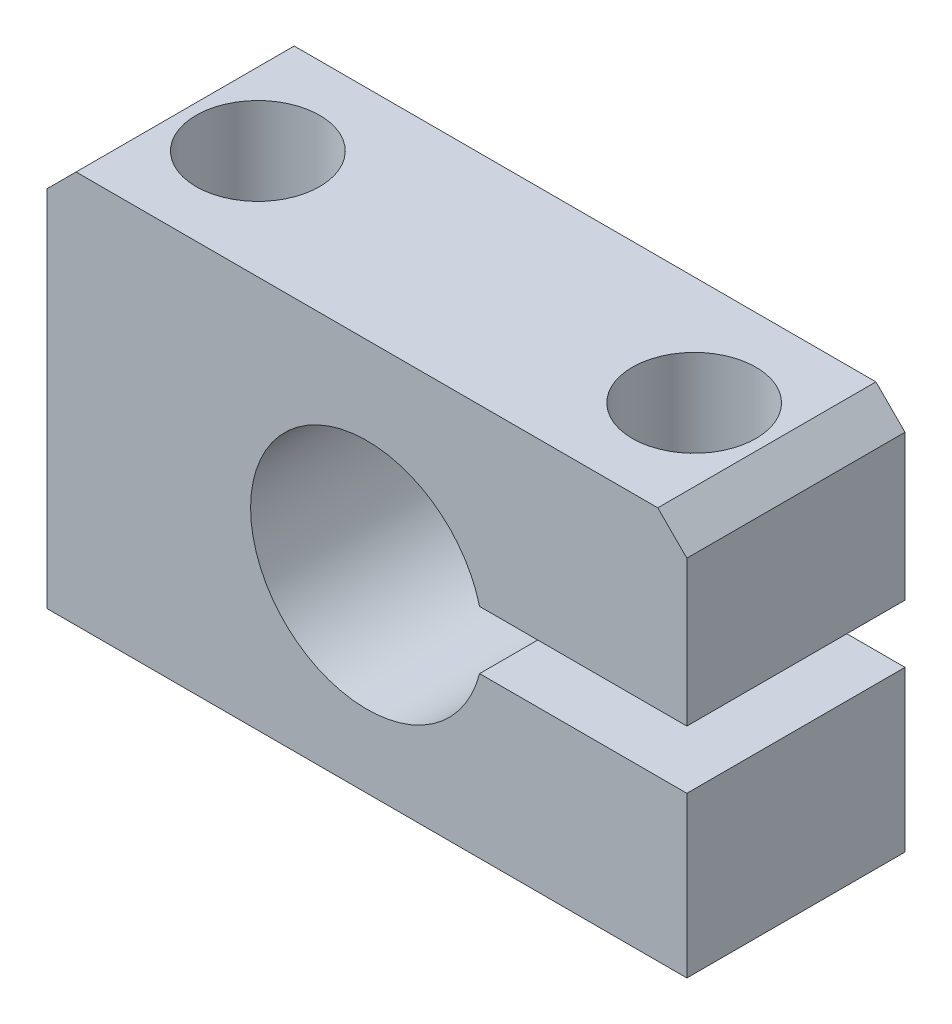
from build123d import *

# Parameters (mm, degrees)
SKETCH1_W                                           = 44
SKETCH1_H                                           = 27
SKETCH1_R                                           = 8
BOSS_EXTRUDE1_DEPTH                                 = 15
CBORE_FOR_M5_HEX_SOCKET_HEAD_CAP_SCREW1_D           = 5.5
CBORE_FOR_M5_HEX_SOCKET_HEAD_CAP_SCREW1_DEPTH       = 27
CBORE_FOR_M5_HEX_SOCKET_HEAD_CAP_SCREW1_CBORE_D     = 8.5
CBORE_FOR_M5_HEX_SOCKET_HEAD_CAP_SCREW1_CBORE_DEPTH = 6
CHAMFER1_SIZE                                       = 2
CUT_EXTRUDE1_REACH                                  = 17


with BuildPart() as part:
    # Sketch1 → Boss-Extrude1 (new body)
    with BuildSketch(Plane.XY):
        with Locations((0, 13.5)):
            Rectangle(SKETCH1_W, SKETCH1_H)
        with Locations((0, 13)):
            Circle(SKETCH1_R, mode=Mode.SUBTRACT)
    extrude(amount=BOSS_EXTRUDE1_DEPTH)

    # CBORE for M5 Hex Socket Head Cap Screw1
    with Locations(Plane(origin=(-15, 27, 7.5), x_dir=(1, 0, 0), z_dir=(0, 1, 0))):
        with Locations((0, 0), (30, 0)):
            CounterBoreHole(CBORE_FOR_M5_HEX_SOCKET_HEAD_CAP_SCREW1_D / 2, CBORE_FOR_M5_HEX_SOCKET_HEAD_CAP_SCREW1_CBORE_D / 2, CBORE_FOR_M5_HEX_SOCKET_HEAD_CAP_SCREW1_CBORE_DEPTH, depth=CBORE_FOR_M5_HEX_SOCKET_HEAD_CAP_SCREW1_DEPTH)

    # Chamfer1
    chamfer1_edges = [part.edges().sort_by_distance(p)[0] for p in [
        (-22, 27, 7.5),
        (22, 27, 7.5),
    ]]
    chamfer(chamfer1_edges, length=CHAMFER1_SIZE)

    # Sketch4 → Cut-Extrude1 (cut, up to next)
    with BuildSketch(Plane.XY.offset(15), mode=Mode.PRIVATE) as cut_extrude1_sk1:
        with BuildLine():
            Line((7.745966692, 15), (22, 15))
            Line((22, 15), (22, 11))
            Line((22, 11), (7.745966692, 11))
            ThreePointArc((7.745966692, 11), (8, 13), (7.745966692, 15))
        make_face()
    cut_extrude1_tool1 = extrude(cut_extrude1_sk1.sketch, amount=-CUT_EXTRUDE1_REACH, mode=Mode.PRIVATE) & part.part
    add(cut_extrude1_tool1.solids().sort_by_distance((14.957731, 13, 15))[0], mode=Mode.SUBTRACT)


solid = part.part
